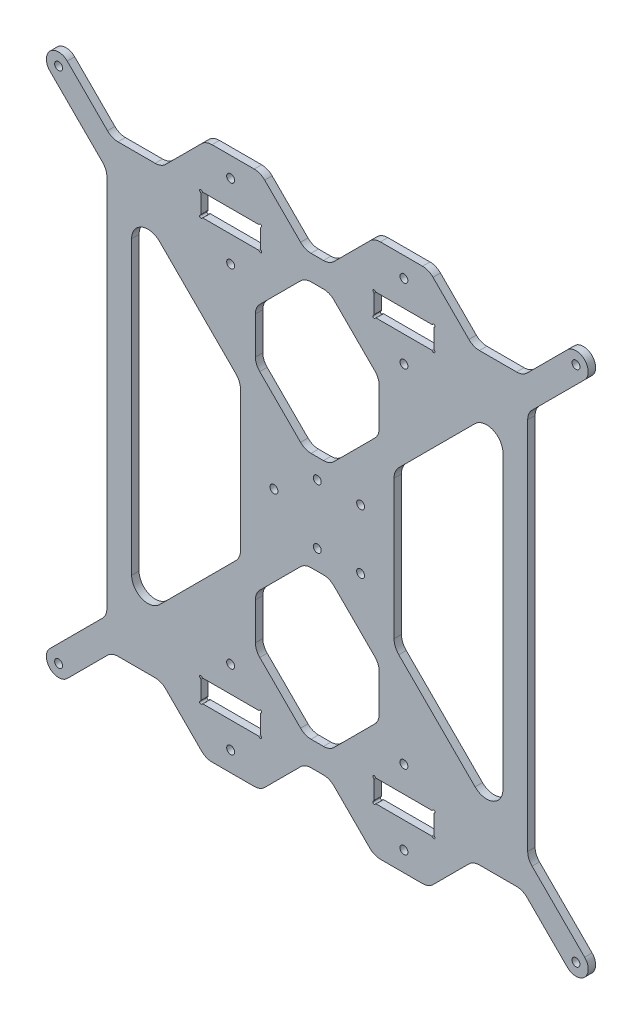
from build123d import *

# Parameters (mm, degrees)
MODEL_R                 = 1.5999965
MODEL_R_2               = 1.600003
MODEL_R_3               = 1.6
SALIENTE_EXTRUIR1_DEPTH = 3


with BuildPart() as part:
    # Model → Saliente-Extruir1 (new body)
    with BuildSketch(Plane.XY):
        with BuildLine():
            Line((91.891901855, 29.145757217), (77.406620855, 43.631041217))
            ThreePointArc((77.406620855, 43.631041217), (75.460078557, 44.931675348), (73.163976855, 45.388395217))
            Line((73.163976855, 45.388395217), (58.134539855, 45.388395217))
            ThreePointArc((58.134539855, 45.388395217), (55.838441731, 44.931674465), (53.891902855, 43.631041217))
            Line((53.891902855, 43.631041217), (37.649257855, 27.388396217))
            ThreePointArc((37.649257855, 27.388396217), (30.649258355, 27.388395717), (30.649257855, 34.388395217))
            Line((30.649257855, 34.388395217), (51.891898855, 55.631036217))
            ThreePointArc((51.891898855, 55.631036217), (53.192536829, 57.577577677), (53.649259855, 59.873680217))
            Line((53.649259855, 59.873680217), (53.649259855, 210.903117217))
            ThreePointArc((53.649259855, 210.903117217), (53.192536981, 213.199219819), (51.891898855, 215.145761217))
            Line((51.891898855, 215.145761217), (30.649257855, 236.388402217))
            ThreePointArc((30.649257855, 236.388402217), (30.649258355, 243.388401717), (37.649257855, 243.388401217))
            Line((37.649257855, 243.388401217), (53.891878265, 227.145780807))
            ThreePointArc((53.891878265, 227.145780807), (55.838418358, 225.845144299), (58.134518952, 225.388421494))
            Line((58.134518952, 225.388421494), (73.164016672, 225.388421494))
            ThreePointArc((73.164016672, 225.388421494), (75.460119123, 225.845142352), (77.406661531, 227.145777992))
            Line((77.406661531, 227.145777992), (91.891954489, 241.631050033))
            ThreePointArc((91.891954489, 241.631050033), (93.838495239, 242.931685482), (96.13459594, 243.388407531))
            Line((96.13459594, 243.388407531), (113.16403394, 243.388393472))
            ThreePointArc((113.16403394, 243.388393472), (115.46013395, 242.931667785), (117.406672489, 241.63102897))
            Line((117.406672489, 241.63102897), (131.891942531, 227.145733012))
            ThreePointArc((131.891942531, 227.145733012), (133.838482181, 225.845097391), (136.13458208, 225.388375509))
            Line((136.13458208, 225.388375509), (141.16401908, 225.388371357))
            ThreePointArc((141.16401908, 225.388371357), (143.460119545, 225.845089905), (145.406661531, 227.145721855))
            Line((145.406661531, 227.145721855), (159.891954489, 241.630993897))
            ThreePointArc((159.891954489, 241.630993897), (161.838495239, 242.931629346), (164.13459594, 243.388351394))
            Line((164.13459594, 243.388351394), (181.16403394, 243.388337336))
            ThreePointArc((181.16403394, 243.388337336), (183.46013395, 242.931611648), (185.406672489, 241.630972833))
            Line((185.406672489, 241.630972833), (199.891941531, 227.145676875))
            ThreePointArc((199.891941531, 227.145676875), (201.838482567, 225.84504068), (204.13458408, 225.388319373))
            Line((204.13458408, 225.388319373), (219.163901188, 225.388319373))
            ThreePointArc((219.163901188, 225.388319373), (221.460001744, 225.845042162), (223.406541817, 227.145678627))
            Line((223.406541817, 227.145678627), (239.649264855, 243.388401217))
            ThreePointArc((239.649264855, 243.388401217), (246.649263855, 243.388401217), (246.649263855, 236.388402217))
            Line((246.649263855, 236.388402217), (225.406622855, 215.145761217))
            ThreePointArc((225.406622855, 215.145761217), (224.105984882, 213.199219756), (223.649261855, 210.903117217))
            Line((223.649261855, 210.903117217), (223.649261855, 150.338145402))
            Line((223.649261855, 150.338145402), (223.649261855, 120.438651748))
            Line((223.649261855, 120.438651748), (223.649261855, 59.873679903))
            ThreePointArc((223.649261855, 59.873679903), (224.105984789, 57.577577469), (225.406622855, 55.631036217))
            Line((225.406622855, 55.631036217), (246.649263855, 34.388395217))
            ThreePointArc((246.649263855, 34.388395217), (246.649263855, 27.388396217), (239.649264855, 27.388396217))
            Line((239.649264855, 27.388396217), (223.406618855, 43.631041217))
            ThreePointArc((223.406618855, 43.631041217), (221.460080284, 44.931673893), (219.163982855, 45.388395217))
            Line((219.163982855, 45.388395217), (204.134544855, 45.388395217))
            ThreePointArc((204.134544855, 45.388395217), (201.838442964, 44.931675804), (199.891900855, 43.631041217))
            Line((199.891900855, 43.631041217), (185.406619855, 29.145757217))
            ThreePointArc((185.406619855, 29.145757217), (183.460080242, 27.845120009), (181.163979855, 27.388396217))
            Line((181.163979855, 27.388396217), (164.134541855, 27.388396217))
            ThreePointArc((164.134541855, 27.388396217), (161.838441531, 27.845120161), (159.891901855, 29.145757217))
            Line((159.891901855, 29.145757217), (145.406620855, 43.631041217))
            ThreePointArc((145.406620855, 43.631041217), (143.460079942, 44.931674774), (141.163979855, 45.388395217))
            Line((141.163979855, 45.388395217), (136.134542855, 45.388395217))
            ThreePointArc((136.134542855, 45.388395217), (133.838442579, 44.93167523), (131.891901855, 43.631041217))
            Line((131.891901855, 43.631041217), (117.406619855, 29.145757217))
            ThreePointArc((117.406619855, 29.145757217), (115.460080242, 27.845120009), (113.163979855, 27.388396217))
            Line((113.163979855, 27.388396217), (96.134541855, 27.388396217))
            ThreePointArc((96.134541855, 27.388396217), (93.838441531, 27.845120161), (91.891901855, 29.145757217))
        make_face()
        with Locations((243.149264355, 30.888395717)):
            Circle(MODEL_R, mode=Mode.SUBTRACT)
        with Locations((34.149257855, 30.888395717)):
            Circle(MODEL_R_2, mode=Mode.SUBTRACT)
        with Locations((173.649260855, 35.388399217)):
            Circle(MODEL_R_3, mode=Mode.SUBTRACT)
        with Locations((103.649260855, 35.388399217)):
            Circle(MODEL_R_3, mode=Mode.SUBTRACT)
        with Locations((173.649260855, 65.388399217)):
            Circle(MODEL_R_3, mode=Mode.SUBTRACT)
        with Locations((103.649260855, 65.388399217)):
            Circle(MODEL_R_3, mode=Mode.SUBTRACT)
        with Locations((156.149260855, 123.388399217)):
            Circle(MODEL_R_3, mode=Mode.SUBTRACT)
        with Locations((121.149260855, 135.388399217)):
            Circle(MODEL_R_3, mode=Mode.SUBTRACT)
        with Locations((156.149260855, 147.388399217)):
            Circle(MODEL_R_3, mode=Mode.SUBTRACT)
        with Locations((243.149264355, 239.888401717)):
            Circle(MODEL_R, mode=Mode.SUBTRACT)
        with Locations((34.149257855, 239.888401717)):
            Circle(MODEL_R_2, mode=Mode.SUBTRACT)
        with Locations((138.649260855, 123.388399217)):
            Circle(MODEL_R_3, mode=Mode.SUBTRACT)
        with Locations((138.649260855, 147.388399217)):
            Circle(MODEL_R_3, mode=Mode.SUBTRACT)
        with Locations((173.649308336, 235.388340539)):
            Circle(MODEL_R_3, mode=Mode.SUBTRACT)
        with Locations((103.649308336, 235.388398327)):
            Circle(MODEL_R_3, mode=Mode.SUBTRACT)
        with Locations((173.64928357, 205.388340539)):
            Circle(MODEL_R_3, mode=Mode.SUBTRACT)
        with Locations((103.64928357, 205.388398327)):
            Circle(MODEL_R_3, mode=Mode.SUBTRACT)
        with BuildLine():
            Line((171.582364655, 168.121494717), (202.382365755, 198.921493617))
            ThreePointArc((202.382365755, 198.921493617), (209.574982452, 200.35219757), (213.649270855, 194.254589617))
            Line((213.649270855, 194.254589617), (213.649270855, 76.522207817))
            ThreePointArc((213.649270855, 76.522207817), (209.574979057, 70.42460806), (202.382365755, 71.855303817))
            Line((202.382365755, 71.855303817), (171.582364655, 102.655302717))
            ThreePointArc((171.582364655, 102.655302717), (170.151663348, 104.796496729), (169.649267555, 107.322207817))
            Line((169.649267555, 107.322207817), (169.649267555, 163.454588517))
            ThreePointArc((169.649267555, 163.454588517), (170.151663221, 165.980300161), (171.582364655, 168.121494717))
        make_face(mode=Mode.SUBTRACT)
        with BuildLine():
            Line((131.891901855, 57.145761217), (115.406619855, 73.631039217))
            ThreePointArc((115.406619855, 73.631039217), (114.105983723, 75.57757906), (113.649260855, 77.873679217))
            Line((113.649260855, 77.873679217), (113.649260855, 92.903117217))
            ThreePointArc((113.649260855, 92.903117217), (114.105983647, 95.199217405), (115.406619855, 97.145757217))
            Line((115.406619855, 97.145757217), (131.891901855, 113.631040217))
            ThreePointArc((131.891901855, 113.631040217), (133.83844216, 114.93167654), (136.134542855, 115.388399217))
            Line((136.134542855, 115.388399217), (141.163979855, 115.388399217))
            ThreePointArc((141.163979855, 115.388399217), (143.460080582, 114.931676616), (145.406620855, 113.631040217))
            Line((145.406620855, 113.631040217), (161.891901855, 97.145757217))
            ThreePointArc((161.891901855, 97.145757217), (163.192538601, 95.19921752), (163.649261855, 92.903117217))
            Line((163.649261855, 92.903117217), (163.649261855, 77.873679217))
            ThreePointArc((163.649261855, 77.873679217), (163.192538601, 75.577578913), (161.891901855, 73.631039217))
            Line((161.891901855, 73.631039217), (145.406620855, 57.145761217))
            ThreePointArc((145.406620855, 57.145761217), (143.460080875, 55.845123589), (141.163979855, 55.388400217))
            Line((141.163979855, 55.388400217), (136.134542855, 55.388400217))
            ThreePointArc((136.134542855, 55.388400217), (133.838441835, 55.845123589), (131.891901855, 57.145761217))
        make_face(mode=Mode.SUBTRACT)
        with BuildLine():
            Line((161.891901855, 173.631040217), (145.406620855, 157.145757217))
            ThreePointArc((145.406620855, 157.145757217), (143.46008055, 155.845120893), (141.163979855, 155.388398217))
            Line((141.163979855, 155.388398217), (136.134542855, 155.388398217))
            ThreePointArc((136.134542855, 155.388398217), (133.838442129, 155.845120817), (131.891901855, 157.145757217))
            Line((131.891901855, 157.145757217), (115.406619855, 173.631040217))
            ThreePointArc((115.406619855, 173.631040217), (114.105985205, 175.577576266), (113.649260855, 177.873672072))
            Line((113.649260855, 177.873672072), (113.649273262, 192.903110072))
            ThreePointArc((113.649273262, 192.903110072), (114.105998026, 195.199209852), (115.406635765, 197.145748621))
            Line((115.406635765, 197.145748621), (131.891931374, 213.631013012))
            ThreePointArc((131.891931374, 213.631013012), (133.838472428, 214.931649033), (136.134573825, 215.388370509))
            Line((136.134573825, 215.388370509), (141.164010825, 215.388366357))
            ThreePointArc((141.164010825, 215.388366357), (143.460111468, 214.93164109), (145.406650374, 213.631001855))
            Line((145.406650374, 213.631001855), (161.891917765, 197.145710246))
            ThreePointArc((161.891917765, 197.145710246), (163.192552904, 195.199169476), (163.649274262, 192.903068795))
            Line((163.649274262, 192.903068795), (163.649261855, 177.873630795))
            ThreePointArc((163.649261855, 177.873630795), (163.192529145, 175.577557083), (161.891901855, 173.631040217))
        make_face(mode=Mode.SUBTRACT)
        with BuildLine():
            Line((185.699262844, 46.754376882), (185.699265844, 54.022337882))
            ThreePointArc((185.699265844, 54.022337882), (185.766252876, 54.272336749), (185.949264341, 54.455349044))
            ThreePointArc((185.949264341, 54.455349044), (186.052816334, 55.241915129), (185.266250546, 55.138360882))
            ThreePointArc((185.266250546, 55.138360882), (185.083237844, 54.95534818), (184.833237844, 54.888360882))
            Line((184.833237844, 54.888360882), (162.465288844, 54.888360882))
            ThreePointArc((162.465288844, 54.888360882), (162.215288506, 54.955348031), (162.032275546, 55.138360882))
            ThreePointArc((162.032275546, 55.138360882), (161.24570966, 55.241916068), (161.349261341, 54.45534972))
            ThreePointArc((161.349261341, 54.45534972), (161.532272978, 54.272337134), (161.599259844, 54.022337882))
            Line((161.599259844, 54.022337882), (161.599262844, 46.754376882))
            ThreePointArc((161.599262844, 46.754376882), (161.532275695, 46.504376544), (161.349262844, 46.321363584))
            ThreePointArc((161.349262844, 46.321363584), (161.245709417, 45.534798304), (162.032275006, 45.638349378))
            ThreePointArc((162.032275006, 45.638349378), (162.215287593, 45.821361016), (162.465286844, 45.888347882))
            Line((162.465286844, 45.888347882), (184.833239844, 45.888347882))
            ThreePointArc((184.833239844, 45.888347882), (185.083238712, 45.82136085), (185.266251006, 45.638349385))
            ThreePointArc((185.266251006, 45.638349385), (186.052816484, 45.534799151), (185.949262844, 46.32136418))
            ThreePointArc((185.949262844, 46.32136418), (185.766250143, 46.504376882), (185.699262844, 46.754376882))
        make_face(mode=Mode.SUBTRACT)
        with BuildLine():
            Line((92.465262855, 45.888325217), (114.833215855, 45.888325217))
            ThreePointArc((114.833215855, 45.888325217), (115.083214722, 45.821338185), (115.266227017, 45.63832672))
            ThreePointArc((115.266227017, 45.63832672), (116.052792494, 45.534776486), (115.949238855, 46.321341515))
            ThreePointArc((115.949238855, 46.321341515), (115.766226153, 46.504354217), (115.699238855, 46.754354217))
            Line((115.699238855, 46.754354217), (115.699241855, 54.022315217))
            ThreePointArc((115.699241855, 54.022315217), (115.766228887, 54.272314084), (115.949240351, 54.455326379))
            ThreePointArc((115.949240351, 54.455326379), (116.052792345, 55.241892463), (115.266226557, 55.138338217))
            ThreePointArc((115.266226557, 55.138338217), (115.083213855, 54.955325515), (114.833213855, 54.888338217))
            Line((114.833213855, 54.888338217), (92.465264855, 54.888338217))
            ThreePointArc((92.465264855, 54.888338217), (92.215264517, 54.955325366), (92.032251557, 55.138338217))
            ThreePointArc((92.032251557, 55.138338217), (91.24568567, 55.241893403), (91.349237351, 54.455327055))
            ThreePointArc((91.349237351, 54.455327055), (91.532248989, 54.272314469), (91.599235855, 54.022315217))
            Line((91.599235855, 54.022315217), (91.599238855, 46.754354217))
            ThreePointArc((91.599238855, 46.754354217), (91.532251706, 46.504353879), (91.349238855, 46.321340919))
            ThreePointArc((91.349238855, 46.321340919), (91.245685428, 45.534775639), (92.032251017, 45.638326713))
            ThreePointArc((92.032251017, 45.638326713), (92.215263603, 45.821338351), (92.465262855, 45.888325217))
        make_face(mode=Mode.SUBTRACT)
        with BuildLine():
            Line((107.649254155, 163.454589617), (107.649254155, 107.322208917))
            ThreePointArc((107.649254155, 107.322208917), (107.146858489, 104.796497272), (105.716157055, 102.655302717))
            Line((105.716157055, 102.655302717), (74.916155955, 71.855303817))
            ThreePointArc((74.916155955, 71.855303817), (67.723539258, 70.424599863), (63.649250855, 76.522207817))
            Line((63.649250855, 76.522207817), (63.649250855, 194.254589617))
            ThreePointArc((63.649250855, 194.254589617), (67.723542654, 200.352189373), (74.916155955, 198.921493617))
            Line((74.916155955, 198.921493617), (105.716157055, 168.121494717))
            ThreePointArc((105.716157055, 168.121494717), (107.146858362, 165.980300704), (107.649254155, 163.454589617))
        make_face(mode=Mode.SUBTRACT)
        with BuildLine():
            Line((185.699300942, 224.022252927), (185.699297942, 216.754291927))
            ThreePointArc((185.699297942, 216.754291927), (185.766284768, 216.504293004), (185.949296081, 216.321280558))
            ThreePointArc((185.949296081, 216.321280558), (186.052847425, 215.534714388), (185.266281723, 215.638269284))
            ThreePointArc((185.266281723, 215.638269284), (185.083269172, 215.821282137), (184.833269227, 215.888269641))
            Line((184.833269227, 215.888269641), (162.465320227, 215.888288107))
            ThreePointArc((162.465320227, 215.888288107), (162.215319834, 215.821301164), (162.032306723, 215.638288465))
            ThreePointArc((162.032306723, 215.638288465), (161.245740751, 215.534733928), (161.349293081, 216.321300191))
            ThreePointArc((161.349293081, 216.321300191), (161.53230487, 216.504312626), (161.599291942, 216.754311822))
            Line((161.599291942, 216.754311822), (161.599300942, 224.022272822))
            ThreePointArc((161.599300942, 224.022272822), (161.532313999, 224.272273215), (161.3493013, 224.455286327))
            ThreePointArc((161.3493013, 224.455286327), (161.245748522, 225.241851691), (162.032314025, 225.138299968))
            ThreePointArc((162.032314025, 225.138299968), (162.215326461, 224.95528818), (162.465325657, 224.888301107))
            Line((162.465325657, 224.888301107), (184.833278657, 224.888282641))
            ThreePointArc((184.833278657, 224.888282641), (185.08327758, 224.955269467), (185.266290025, 225.13828078))
            ThreePointArc((185.266290025, 225.13828078), (186.052855588, 225.241830366), (185.9493013, 224.455265422))
            ThreePointArc((185.9493013, 224.455265422), (185.766288447, 224.272252871), (185.699300942, 224.022252927))
        make_face(mode=Mode.SUBTRACT)
        with BuildLine():
            Line((92.465301668, 224.88838156), (114.833254668, 224.888363094))
            ThreePointArc((114.833254668, 224.888363094), (115.08325359, 224.95534992), (115.266266036, 225.138361233))
            ThreePointArc((115.266266036, 225.138361233), (116.052831599, 225.241910819), (115.94927731, 224.455345875))
            ThreePointArc((115.94927731, 224.455345875), (115.766264457, 224.272333324), (115.699276953, 224.02233338))
            Line((115.699276953, 224.02233338), (115.699273953, 216.75437238))
            ThreePointArc((115.699273953, 216.75437238), (115.766260778, 216.504373457), (115.949272092, 216.321361011))
            ThreePointArc((115.949272092, 216.321361011), (116.052823436, 215.534794841), (115.266257733, 215.638349737))
            ThreePointArc((115.266257733, 215.638349737), (115.083245183, 215.82136259), (114.833245238, 215.888350094))
            Line((114.833245238, 215.888350094), (92.465296238, 215.88836856))
            ThreePointArc((92.465296238, 215.88836856), (92.215295844, 215.821381617), (92.032282733, 215.638368918))
            ThreePointArc((92.032282733, 215.638368918), (91.245716761, 215.534814381), (91.349269092, 216.321380643))
            ThreePointArc((91.349269092, 216.321380643), (91.53228088, 216.504393079), (91.599267953, 216.754392275))
            Line((91.599267953, 216.754392275), (91.599276953, 224.022353275))
            ThreePointArc((91.599276953, 224.022353275), (91.53229001, 224.272353668), (91.34927731, 224.45536678))
            ThreePointArc((91.34927731, 224.45536678), (91.245724533, 225.241932144), (92.032290036, 225.138380421))
            ThreePointArc((92.032290036, 225.138380421), (92.215302471, 224.955368633), (92.465301668, 224.88838156))
        make_face(mode=Mode.SUBTRACT)
    extrude(amount=SALIENTE_EXTRUIR1_DEPTH)


solid = part.part
